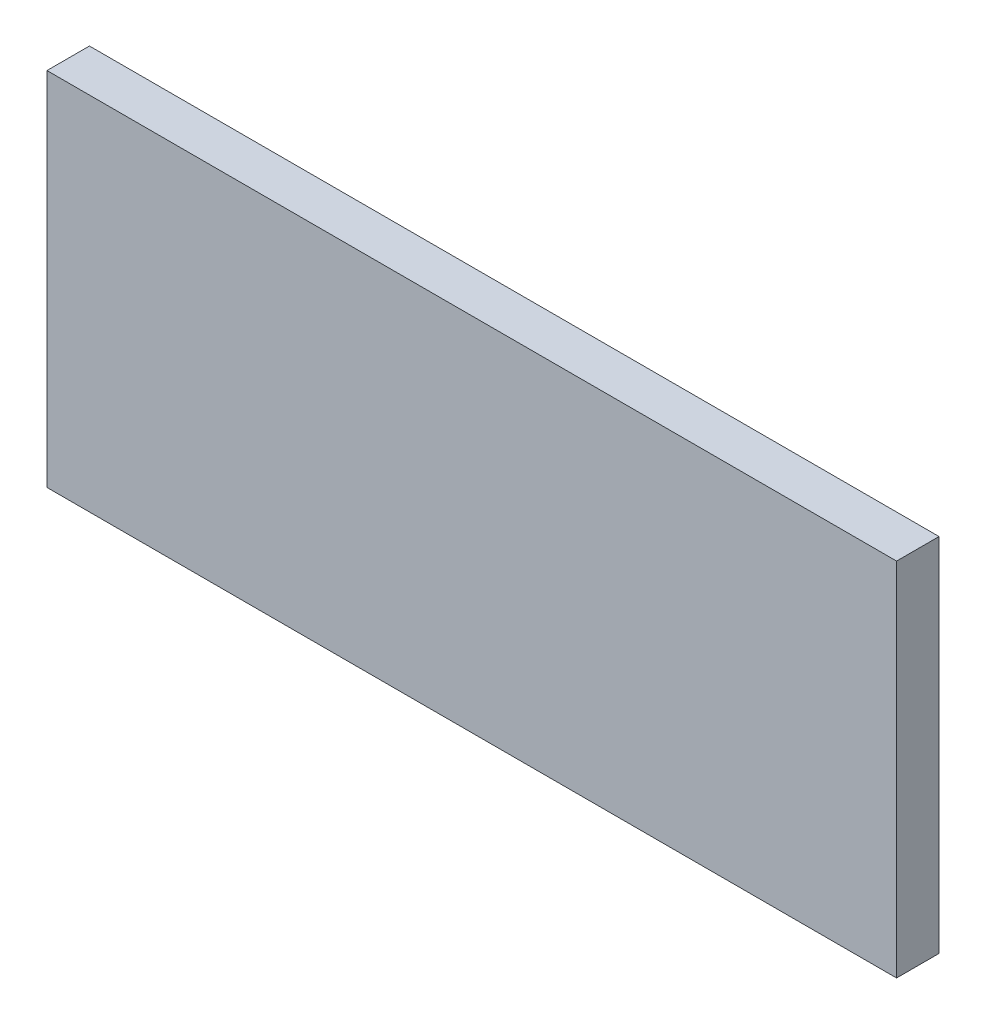
from build123d import *

# Parameters (mm, degrees)
SKETCH1_W           = 2000
SKETCH1_H           = 850
BOSS_EXTRUDE1_DEPTH = 100


with BuildPart() as part:
    # Sketch1 → Boss-Extrude1 (new body)
    with BuildSketch(Plane.XY):
        with Locations((-1000, -425)):
            Rectangle(SKETCH1_W, SKETCH1_H)
    extrude(amount=BOSS_EXTRUDE1_DEPTH)


solid = part.part
